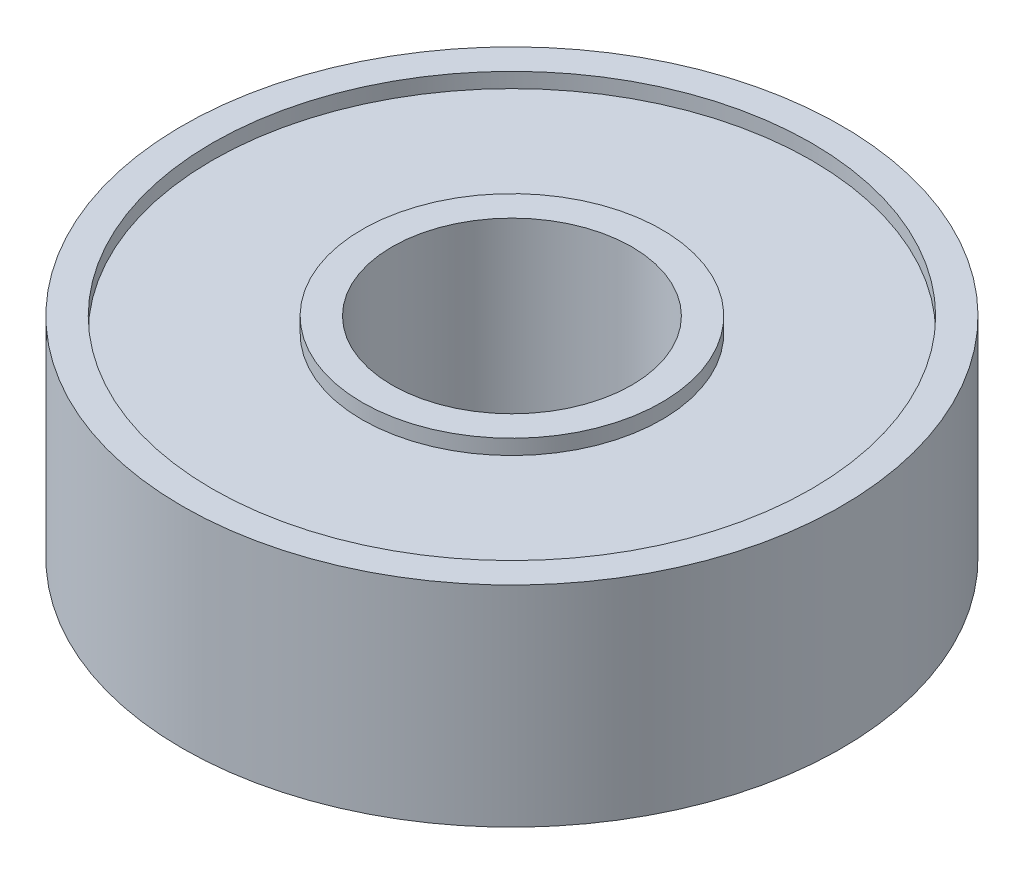
from build123d import *

# Parameters (mm, degrees)
SKETCH1_R           = 11
BOSS_EXTRUDE1_DEPTH = 7
SKETCH2_R           = 4
CUT_EXTRUDE1_DEPTH  = 7
SKETCH3_R           = 10
SKETCH3_R_2         = 5
CUT_EXTRUDE2_DEPTH  = 0.5
SKETCH4_R           = 10
SKETCH4_R_2         = 5
CUT_EXTRUDE3_DEPTH  = 0.5


with BuildPart() as part:
    # Sketch1 → Boss-Extrude1 (new body)
    with BuildSketch(Plane(origin=(0, 0, 0), x_dir=(1, 0, 0), z_dir=(0, 1, 0))):
        Circle(SKETCH1_R)
    extrude(amount=BOSS_EXTRUDE1_DEPTH)

    # Sketch2 → Cut-Extrude1 (cut)
    with BuildSketch(Plane(origin=(0, 7, 0), x_dir=(1, 0, 0), z_dir=(0, 1, 0))):
        Circle(SKETCH2_R)
    extrude(amount=-CUT_EXTRUDE1_DEPTH, mode=Mode.SUBTRACT)

    # Sketch3 → Cut-Extrude2 (cut)
    with BuildSketch(Plane(origin=(0, 7, 0), x_dir=(1, 0, 0), z_dir=(0, 1, 0))):
        Circle(SKETCH3_R)
        Circle(SKETCH3_R_2, mode=Mode.SUBTRACT)
    extrude(amount=-CUT_EXTRUDE2_DEPTH, mode=Mode.SUBTRACT)

    # Sketch4 → Cut-Extrude3 (cut)
    with BuildSketch(Plane.XZ):
        Circle(SKETCH4_R)
        Circle(SKETCH4_R_2, mode=Mode.SUBTRACT)
    extrude(amount=-CUT_EXTRUDE3_DEPTH, mode=Mode.SUBTRACT)


solid = part.part
